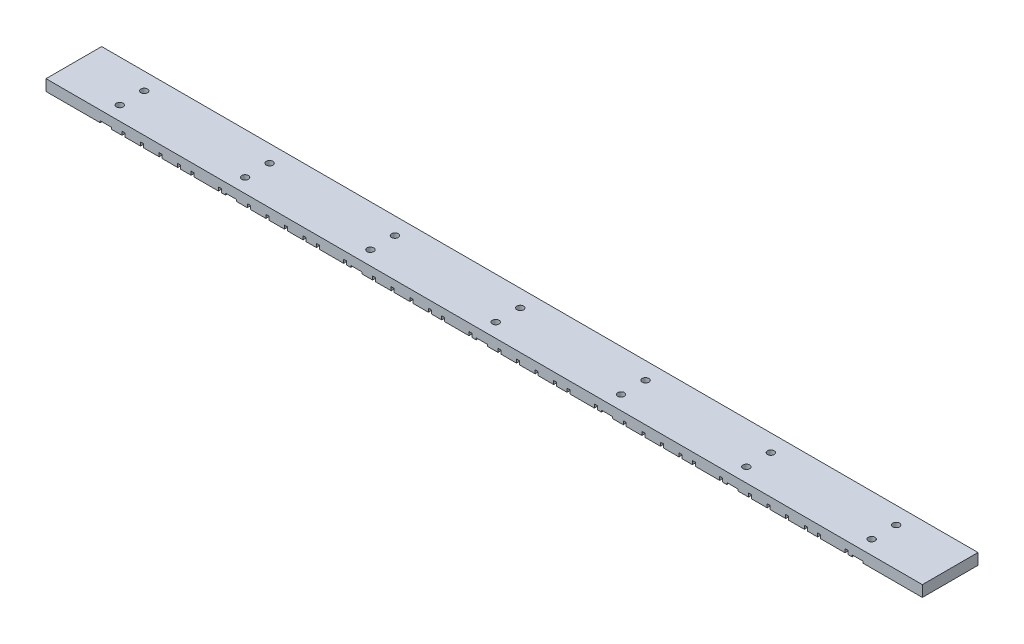
from build123d import *

# Parameters (mm, degrees)
SKETCH2_W           = 500
SKETCH2_H           = 31.75
BOSS_EXTRUDE1_DEPTH = 6.35
CUT_EXTRUDE2_DEPTH  = 32.75
CUT_EXTRUDE4_DEPTH  = 32.75
SKETCH6_R           = 1.89865
CUT_EXTRUDE3_DEPTH  = 6.35


with BuildPart() as part:
    # Sketch2 → Boss-Extrude1 (new body)
    with BuildSketch(Plane(origin=(0, 98, 0), x_dir=(1, 0, 0), z_dir=(0, 1, 0))):
        with Locations((150, 35.875)):
            Rectangle(SKETCH2_W, SKETCH2_H)
    extrude(amount=BOSS_EXTRUDE1_DEPTH)

    # Sketch5 → Cut-Extrude2 (cut, through all)
    with BuildSketch(Plane(origin=(0, 0, -51.75), x_dir=(-1, 0, 0), z_dir=(0, 0, -1))):
        Polygon((-357.55715, 98), (-357.55715, 100.05715), (-355.85535, 100.05715), (-355.85535, 98), (-341.95715, 98), (-341.95715, 100.05715), (-340.25535, 100.05715), (-340.25535, 98), (-334.35715, 98), (-334.35715, 100.05715), (-332.65535, 100.05715), (-332.65535, 98), (-323.75715, 98), (-323.75715, 100.05715), (-322.05535, 100.05715), (-322.05535, 98), (-313.15715, 98), (-313.15715, 100.05715), (-311.45535, 100.05715), (-311.45535, 98), (-302.55715, 98), (-302.55715, 100.05715), (-300.85535, 100.05715), (-300.85535, 98), (-295.78949815, 98), (-295.78949815, 96.633226224), (-359.074689679, 96.633226224), (-359.074689679, 98), align=None)
        Polygon((-286.05715, 98), (-286.05715, 100.05715), (-284.35535, 100.05715), (-284.35535, 98), (-270.45715, 98), (-270.45715, 100.05715), (-268.75535, 100.05715), (-268.75535, 98), (-262.85715, 98), (-262.85715, 100.05715), (-261.15535, 100.05715), (-261.15535, 98), (-252.25715, 98), (-252.25715, 100.05715), (-250.55535, 100.05715), (-250.55535, 98), (-241.65715, 98), (-241.65715, 100.05715), (-239.95535, 100.05715), (-239.95535, 98), (-231.05715, 98), (-231.05715, 100.05715), (-229.35535, 100.05715), (-229.35535, 98), (-224.28949815, 98), (-224.28949815, 96.633226224), (-287.574689679, 96.633226224), (-287.574689679, 98), align=None)
        Polygon((-214.55715, 98), (-214.55715, 100.05715), (-212.85535, 100.05715), (-212.85535, 98), (-198.95715, 98), (-198.95715, 100.05715), (-197.25535, 100.05715), (-197.25535, 98), (-191.35715, 98), (-191.35715, 100.05715), (-189.65535, 100.05715), (-189.65535, 98), (-180.75715, 98), (-180.75715, 100.05715), (-179.05535, 100.05715), (-179.05535, 98), (-170.15715, 98), (-170.15715, 100.05715), (-168.45535, 100.05715), (-168.45535, 98), (-159.55715, 98), (-159.55715, 100.05715), (-157.85535, 100.05715), (-157.85535, 98), (-152.78949815, 98), (-152.78949815, 96.633226224), (-216.074689679, 96.633226224), (-216.074689679, 98), align=None)
        Polygon((-143.05715, 98), (-143.05715, 100.05715), (-141.35535, 100.05715), (-141.35535, 98), (-127.45715, 98), (-127.45715, 100.05715), (-125.75535, 100.05715), (-125.75535, 98), (-119.85715, 98), (-119.85715, 100.05715), (-118.15535, 100.05715), (-118.15535, 98), (-109.25715, 98), (-109.25715, 100.05715), (-107.55535, 100.05715), (-107.55535, 98), (-98.65715, 98), (-98.65715, 100.05715), (-96.95535, 100.05715), (-96.95535, 98), (-88.05715, 98), (-88.05715, 100.05715), (-86.35535, 100.05715), (-86.35535, 98), (-81.28949815, 98), (-81.28949815, 96.633226224), (-144.574689679, 96.633226224), (-144.574689679, 98), align=None)
        Polygon((-71.55715, 98), (-71.55715, 100.05715), (-69.85535, 100.05715), (-69.85535, 98), (-55.95715, 98), (-55.95715, 100.05715), (-54.25535, 100.05715), (-54.25535, 98), (-48.35715, 98), (-48.35715, 100.05715), (-46.65535, 100.05715), (-46.65535, 98), (-37.75715, 98), (-37.75715, 100.05715), (-36.05535, 100.05715), (-36.05535, 98), (-27.15715, 98), (-27.15715, 100.05715), (-25.45535, 100.05715), (-25.45535, 98), (-16.55715, 98), (-16.55715, 100.05715), (-14.85535, 100.05715), (-14.85535, 98), (-9.78949815, 98), (-9.78949815, 96.633226224), (-73.074689679, 96.633226224), (-73.074689679, 98), align=None)
        Polygon((-0.05715, 98), (-0.05715, 100.05715), (1.64465, 100.05715), (1.64465, 98), (15.54285, 98), (15.54285, 100.05715), (17.24465, 100.05715), (17.24465, 98), (23.14285, 98), (23.14285, 100.05715), (24.84465, 100.05715), (24.84465, 98), (33.74285, 98), (33.74285, 100.05715), (35.44465, 100.05715), (35.44465, 98), (44.34285, 98), (44.34285, 100.05715), (46.04465, 100.05715), (46.04465, 98), (54.94285, 98), (54.94285, 100.05715), (56.64465, 100.05715), (56.64465, 98), (61.71050185, 98), (61.71050185, 96.633226224), (-1.574689679, 96.633226224), (-1.574689679, 98), align=None)
    extrude(amount=-CUT_EXTRUDE2_DEPTH, mode=Mode.SUBTRACT)

    # Sketch7 → Cut-Extrude4 (cut, through all)
    with BuildSketch(Plane.XY.offset(-20)):
        Polygon((-70.246654546, 98), (-69.091918949, 98), (-69.091918949, 99), (-62.741918949, 99), (-62.741918949, 98), (-61.77474032, 98), (-61.77474032, 96.833570425), (-70.246654546, 96.833570425), align=None)
        Polygon((1.253345454, 98), (2.408081051, 98), (2.408081051, 99), (8.758081051, 99), (8.758081051, 98), (9.72525968, 98), (9.72525968, 96.833570425), (1.253345454, 96.833570425), align=None)
        Polygon((72.753345454, 98), (73.908081051, 98), (73.908081051, 99), (80.258081051, 99), (80.258081051, 98), (81.22525968, 98), (81.22525968, 96.833570425), (72.753345454, 96.833570425), align=None)
        Polygon((144.253345454, 98), (145.408081051, 98), (145.408081051, 99), (151.758081051, 99), (151.758081051, 98), (152.72525968, 98), (152.72525968, 96.833570425), (144.253345454, 96.833570425), align=None)
        Polygon((215.753345454, 98), (216.908081051, 98), (216.908081051, 99), (223.258081051, 99), (223.258081051, 98), (224.22525968, 98), (224.22525968, 96.833570425), (215.753345454, 96.833570425), align=None)
        Polygon((287.253345454, 98), (288.408081051, 98), (288.408081051, 99), (294.758081051, 99), (294.758081051, 98), (295.72525968, 98), (295.72525968, 96.833570425), (287.253345454, 96.833570425), align=None)
        Polygon((358.753345454, 98), (359.908081051, 98), (359.908081051, 99), (366.258081051, 99), (366.258081051, 98), (367.22525968, 98), (367.22525968, 96.833570425), (358.753345454, 96.833570425), align=None)
    extrude(amount=-CUT_EXTRUDE4_DEPTH, mode=Mode.SUBTRACT)

    # Sketch6 → Cut-Extrude3 (cut, through all)
    with BuildSketch(Plane(origin=(0, 99, 0), x_dir=(1, 0, 0), z_dir=(0, 1, 0))):
        with Locations((-65.916918949, 28)):
            Circle(SKETCH6_R)
        with Locations((-65.916918949, 42)):
            Circle(SKETCH6_R)
        with Locations((5.583081051, 28)):
            Circle(SKETCH6_R)
        with Locations((5.583081051, 42)):
            Circle(SKETCH6_R)
        with Locations((77.083081051, 28)):
            Circle(SKETCH6_R)
        with Locations((77.083081051, 42)):
            Circle(SKETCH6_R)
        with Locations((148.583081051, 28)):
            Circle(SKETCH6_R)
        with Locations((148.583081051, 42)):
            Circle(SKETCH6_R)
        with Locations((220.083081051, 28)):
            Circle(SKETCH6_R)
        with Locations((220.083081051, 42)):
            Circle(SKETCH6_R)
        with Locations((291.583081051, 28)):
            Circle(SKETCH6_R)
        with Locations((291.583081051, 42)):
            Circle(SKETCH6_R)
        with Locations((363.083081051, 28)):
            Circle(SKETCH6_R)
        with Locations((363.083081051, 42)):
            Circle(SKETCH6_R)
    extrude(amount=CUT_EXTRUDE3_DEPTH, mode=Mode.SUBTRACT)


solid = part.part
